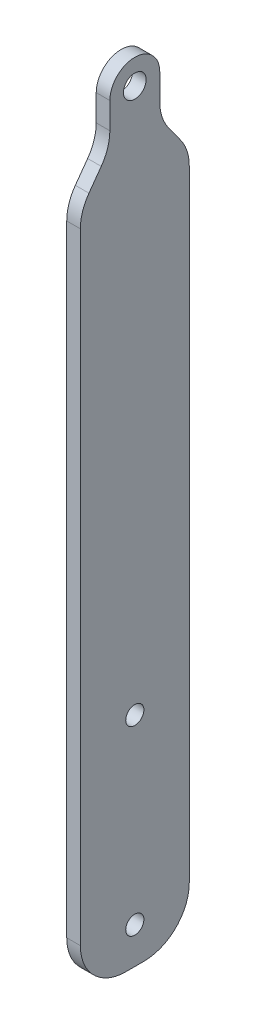
from build123d import *

# Parameters (mm, degrees)
SKETCH1_R           = 2.5
BOSS_EXTRUDE1_DEPTH = 3
BOSS_EXTRUDE2_DEPTH = 2
FILLET4_R           = 10
SKETCH5_R           = 2
CUT_EXTRUDE1_DEPTH  = 6


with BuildPart() as part:
    # Sketch1 → Boss-Extrude1 (new body)
    with BuildSketch(Plane(origin=(18.3, 0, 0), x_dir=(0, 0, -1), z_dir=(1, 0, 0))):
        with BuildLine():
            Line((61.5, -7.353946086), (61.5, -16.353946086))
            Line((61.5, -16.353946086), (55, -25.353946086))
            Line((55, -25.353946086), (55, -175.353946086))
            Line((55, -175.353946086), (79, -175.353946086))
            Line((79, -175.353946086), (79, -25.353946086))
            Line((79, -25.353946086), (72.5, -16.353946086))
            Line((72.5, -16.353946086), (72.5, -7.353946086))
            ThreePointArc((72.5, -7.353946086), (67, -1.853946086), (61.5, -7.353946086))
        make_face()
        with Locations((67, -7.353946086)):
            Circle(SKETCH1_R, mode=Mode.SUBTRACT)
    extrude(amount=BOSS_EXTRUDE1_DEPTH)

    # Sketch4 → Boss-Extrude2 (add)
    with BuildSketch(Plane.ZY.offset(-18.3)):
        with BuildLine():
            Line((-72, -25.353946086), (-75, -175.353946086))
            Line((-75, -175.353946086), (-59, -175.353946086))
            Line((-59, -175.353946086), (-62, -25.353946086))
            ThreePointArc((-62, -25.353946086), (-67, -20.353946086), (-72, -25.353946086))
        make_face()
    extrude(amount=BOSS_EXTRUDE2_DEPTH)

    # Fillet4
    fillet4_edges = [part.edges().sort_by_distance(p)[0] for p in [
        (19.8, -175.353946086, -55),
        (19.8, -175.353946086, -79),
        (19.8, -25.353946086, -55),
        (19.8, -16.353946086, -61.5),
        (19.8, -25.353946086, -79),
        (19.8, -16.353946086, -72.5),
    ]]
    fillet(fillet4_edges, radius=FILLET4_R)

    # Sketch5 → Cut-Extrude1 (cut, through all)
    with BuildSketch(Plane.ZY.offset(-16.3)):
        with Locations((-67, -127.353946086)):
            Circle(SKETCH5_R)
        with Locations((-67, -167.353946086)):
            Circle(SKETCH5_R)
    extrude(amount=-CUT_EXTRUDE1_DEPTH, mode=Mode.SUBTRACT)


solid = part.part
